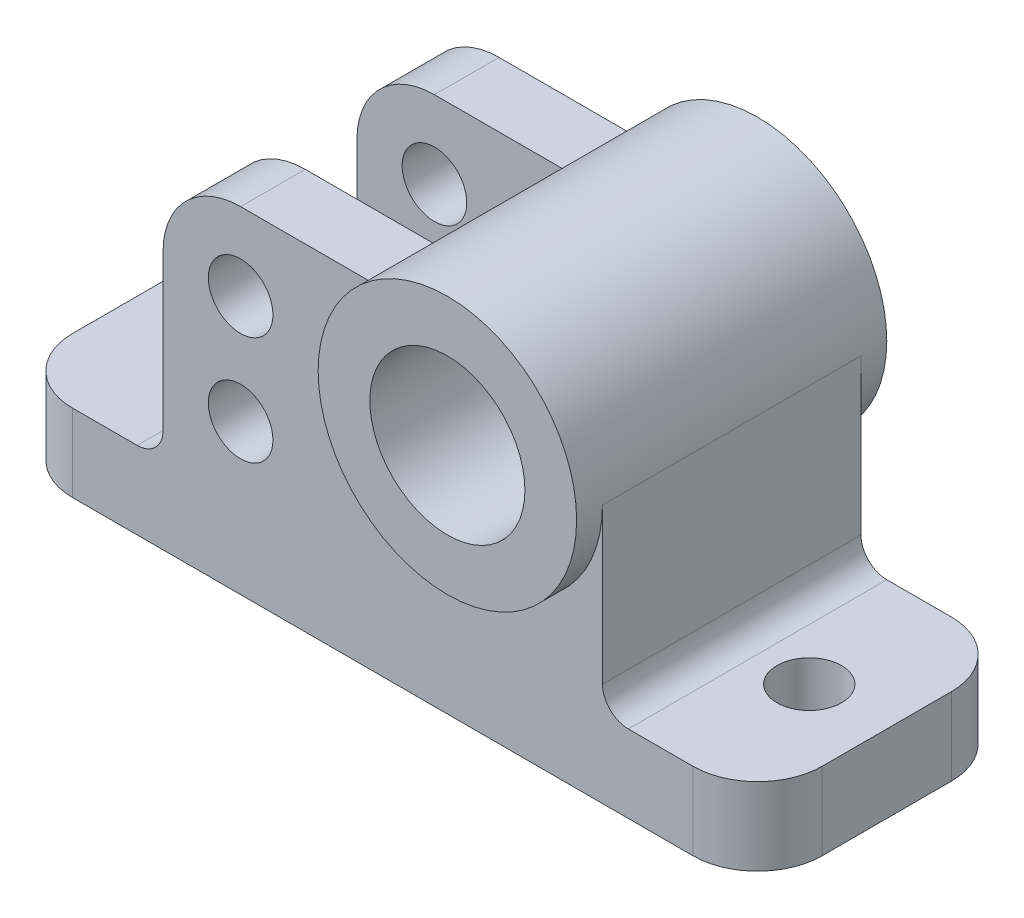
from build123d import *

# Parameters (mm, degrees)
BOSS_EXTRUDE1_DEPTH = 50
FILLET1_R           = 30
SKETCH2_R           = 50
BOSS_EXTRUDE2_DEPTH = 60
SKETCH3_R           = 30
CUT_EXTRUDE1_DEPTH  = 121
FILLET2_R           = 10
CUT_EXTRUDE2_DEPTH  = 25
SKETCH6_R           = 12.5
CUT_EXTRUDE3_DEPTH  = 111
FILLET3_R           = 25
SKETCH10_R          = 12.5
CUT_EXTRUDE5_DEPTH  = 31


with BuildPart() as part:
    # Sketch1 → Boss-Extrude1 (new body, symmetric)
    with BuildSketch(Plane.XY):
        Polygon((0, 0), (290, 0), (290, 30), (230, 30), (230, 130), (60, 130), (60, 30), (0, 30), align=None)
    extrude(amount=BOSS_EXTRUDE1_DEPTH, both=True)

    # Fillet1
    fillet1_edges = [part.edges().sort_by_distance(p)[0] for p in [
        (60, 130, 0),
        (230, 130, 0),
    ]]
    fillet(fillet1_edges, radius=FILLET1_R)

    # Sketch2 → Boss-Extrude2 (add, symmetric)
    with BuildSketch(Plane.XY):
        with Locations((180, 100)):
            Circle(SKETCH2_R)
    extrude(amount=BOSS_EXTRUDE2_DEPTH, both=True)

    # Sketch3 → Cut-Extrude1 (cut, through all)
    with BuildSketch(Plane.XY.offset(60)):
        with Locations((180, 100)):
            Circle(SKETCH3_R)
    extrude(amount=-CUT_EXTRUDE1_DEPTH, mode=Mode.SUBTRACT)

    # Fillet2
    fillet2_edges = [part.edges().sort_by_distance(p)[0] for p in [
        (60, 30, 0),
        (230, 30, 0),
    ]]
    fillet(fillet2_edges, radius=FILLET2_R)

    # Sketch5 → Cut-Extrude2 (cut, symmetric)
    with BuildSketch(Plane.XY):
        with BuildLine():
            Line((140, 130), (60, 130))
            Line((60, 130), (60, 40))
            Line((60, 40), (130, 40))
            Line((130, 40), (130, 100))
            ThreePointArc((130, 100), (132.565835097, 115.811388301), (140, 130))
        make_face()
    extrude(amount=CUT_EXTRUDE2_DEPTH, both=True, mode=Mode.SUBTRACT)

    # Sketch6 → Cut-Extrude3 (cut, through all)
    with BuildSketch(Plane.XY.offset(50)):
        with Locations((90, 100)):
            Circle(SKETCH6_R)
        with Locations((90, 58)):
            Circle(SKETCH6_R)
    extrude(amount=-CUT_EXTRUDE3_DEPTH, mode=Mode.SUBTRACT)

    # Fillet3
    fillet3_edges = [part.edges().sort_by_distance(p)[0] for p in [
        (290, 15, 50),
        (0, 15, -50),
        (0, 15, 50),
        (290, 15, -50),
    ]]
    fillet(fillet3_edges, radius=FILLET3_R)

    # Sketch10 → Cut-Extrude5 (cut, through all)
    with BuildSketch(Plane(origin=(0, 30, 0), x_dir=(1, 0, 0), z_dir=(0, 1, 0))):
        with Locations(Location((30, 0, 0), (0, 0, 270))):  # turned: the seam where the file's is
            Circle(SKETCH10_R)
        with Locations(Location((260, 0, 0), (0, 0, 270))):  # turned: the seam where the file's is
            Circle(SKETCH10_R)
    extrude(amount=-CUT_EXTRUDE5_DEPTH, mode=Mode.SUBTRACT)


solid = part.part
